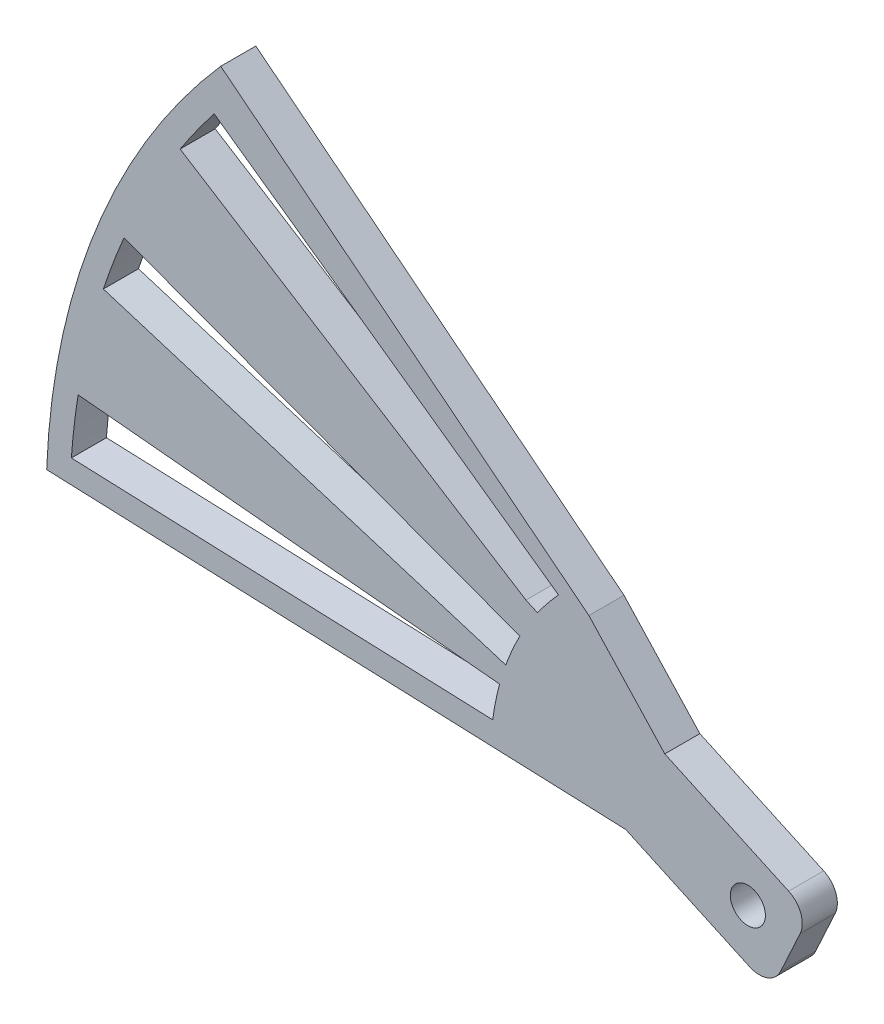
from build123d import *

# Parameters (mm, degrees)
BOSS_EXTRUDE2_DEPTH = 3
CUT_EXTRUDE1_DEPTH  = 72.917502797
SKETCH1_8_R         = 1.5
BOSS_EXTRUDE5_DEPTH = 3
FILLET1_R           = 2


with BuildPart() as part:
    # Sketch1 → Boss-Extrude2 (new body)
    with BuildSketch(Plane.XY):
        with BuildLine():
            Line((-19.985447982, 0.762803358), (-59.956343946, 2.288410074))
            ThreePointArc((-59.956343946, 2.288410074), (-55.730717245, 22.228071336), (-45.073672701, 39.602576043))
            Line((-45.073672701, 39.602576043), (-13.592462366, 14.67122922))
            ThreePointArc((-13.592462366, 14.67122922), (-18.172234131, 8.352838241), (-19.985447982, 0.762803358))
        make_face()
    extrude(amount=BOSS_EXTRUDE2_DEPTH)

    # Sketch1_5 → Cut-Extrude1 (cut, through all)
    with BuildSketch(Plane.XY):
        with BuildLine():
            ThreePointArc((-21.816681027, 2.834154011), (-21.572673921, 4.315059664), (-21.2282638, 5.775882272))
            Line((-21.2282638, 5.775882272), (-57.269563461, 9.175897829))
            ThreePointArc((-57.269563461, 9.175897829), (-57.611850796, 6.698854216), (-57.847050894, 4.209358967))
            Line((-57.847050894, 4.209358967), (-21.816681027, 2.834154011))
        make_face()
        with BuildLine():
            Line((-18.974652115, 13.123988942), (-17.985708937, 12.669422798))
            ThreePointArc((-17.985708937, 12.669422798), (-17.201666988, 13.715052053), (-16.356919422, 14.712280144))
            Line((-16.356919422, 14.712280144), (-16.19149009, 14.894148135))
            Line((-16.19149009, 14.894148135), (-45.633154018, 35.799654388))
            ThreePointArc((-45.633154018, 35.799654388), (-47.133831778, 33.799436415), (-48.546898537, 31.736393028))
            Line((-48.546898537, 31.736393028), (-18.974652115, 13.123988942))
        make_face()
        with BuildLine():
            Line((-55.106686022, 18.090139737), (-20.700540486, 7.449001516))
            ThreePointArc((-20.700540486, 7.449001516), (-20.144482043, 8.843067523), (-19.494667642, 10.19597634))
            Line((-19.494667642, 10.19597634), (-53.343874365, 22.769081398))
            ThreePointArc((-53.343874365, 22.769081398), (-54.275723264, 20.448615214), (-55.106686022, 18.090139737))
        make_face()
    extrude(amount=CUT_EXTRUDE1_DEPTH, mode=Mode.SUBTRACT)

    # Sketch1_8 → Boss-Extrude5 (add)
    with BuildSketch(Plane.XY):
        with BuildLine():
            ThreePointArc((-19.475648091, 4.549629811), (-19.821189154, 2.668419106), (-19.985447982, 0.762803358))
            Line((-19.985447982, 0.762803358), (-10.444898468, 0.398660247))
            Line((-10.444898468, 0.398660247), (1.963879178, -5.305014474))
            Line((1.963879178, -5.305014474), (5.305014474, 1.963879178))
            Line((5.305014474, 1.963879178), (-7.103763171, 7.667553899))
            Line((-7.103763171, 7.667553899), (-13.592462366, 14.67122922))
            ThreePointArc((-13.592462366, 14.67122922), (-14.931769674, 13.305722619), (-16.134512795, 11.818523464))
            ThreePointArc((-16.134512795, 11.818523464), (-18.172234131, 8.352838241), (-19.475648091, 4.549629811))
        make_face()
        Circle(SKETCH1_8_R, mode=Mode.SUBTRACT)
    extrude(amount=BOSS_EXTRUDE5_DEPTH)

    # Fillet1
    fillet1_edges = [part.edges().sort_by_distance(p)[0] for p in [
        (5.305014474, 1.963879178, 1.5),
        (1.963879178, -5.305014474, 1.5),
    ]]
    fillet(fillet1_edges, radius=FILLET1_R)


solid = part.part
